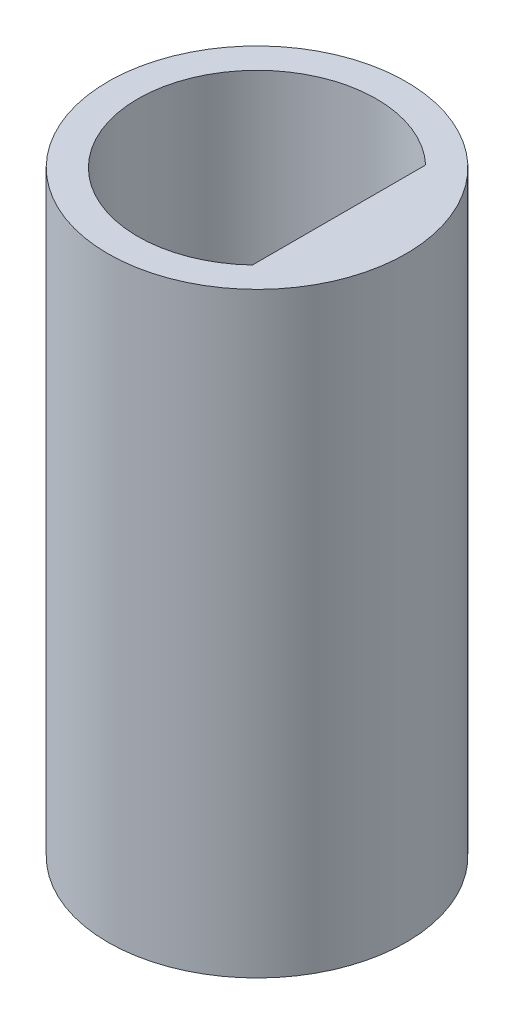
from build123d import *

# Parameters (mm, degrees)
SKETCH1_R           = 2
BOSS_EXTRUDE1_DEPTH = 8


with BuildPart() as part:
    # Sketch1 → Boss-Extrude1 (new body)
    with BuildSketch(Plane(origin=(0, 0, 0), x_dir=(1, 0, 0), z_dir=(0, 1, 0))):
        Circle(SKETCH1_R)
        with BuildLine():
            Line((1.1, 1.161895004), (1.1, -1.161895004))
            ThreePointArc((1.1, -1.161895004), (-1.6, 0), (1.1, 1.161895004))
        make_face(mode=Mode.SUBTRACT)
    extrude(amount=BOSS_EXTRUDE1_DEPTH)


solid = part.part
